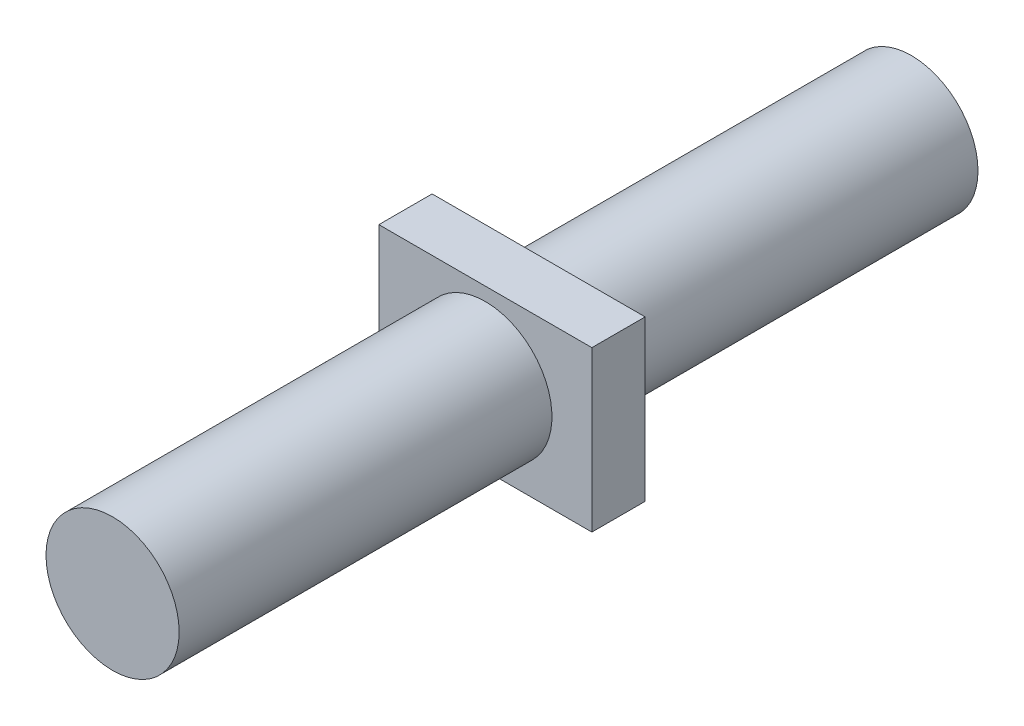
from build123d import *

# Parameters (mm, degrees)
SKETCH1_R                = 12.5
BOSS_EXTRUDE1_DEPTH      = 150
BOSS_EXTRUDE2_START      = 75
SKETCH2_W                = 40
SKETCH2_H                = 30
BOSS_EXTRUDE2_DEPTH      = 5
BOSS_EXTRUDE2_DEPTH_BACK = 5


with BuildPart() as part:
    # Sketch1 → Boss-Extrude1 (new body)
    with BuildSketch(Plane.XY):
        Circle(SKETCH1_R)
    extrude(amount=BOSS_EXTRUDE1_DEPTH)

    # Sketch2 → Boss-Extrude2 (add, two sides)
    with BuildSketch(Plane.XY.offset(BOSS_EXTRUDE2_START)) as boss_extrude2_sk:
        Rectangle(SKETCH2_W, SKETCH2_H)
    extrude(amount=BOSS_EXTRUDE2_DEPTH)
    extrude(boss_extrude2_sk.sketch, amount=-BOSS_EXTRUDE2_DEPTH_BACK)


solid = part.part
